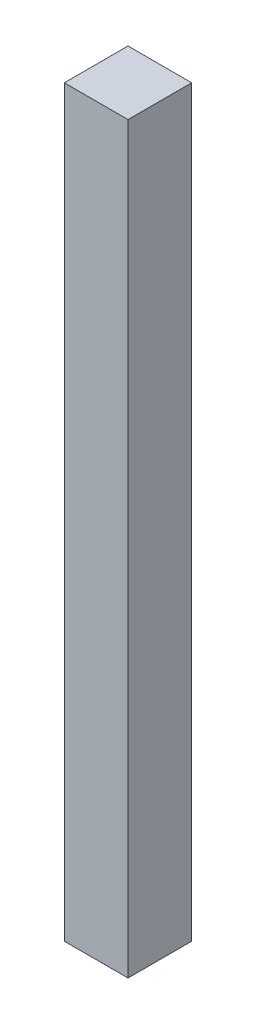
from build123d import *

# Parameters (mm, degrees)
SKETCH1_W           = 60
SKETCH1_H           = 60
BOSS_EXTRUDE1_DEPTH = 700


with BuildPart() as part:
    # Sketch1 → Boss-Extrude1 (new body)
    with BuildSketch(Plane(origin=(0, 0, 0), x_dir=(1, 0, 0), z_dir=(0, 1, 0))):
        with Locations((-58.926858659, -23.233738784)):
            Rectangle(SKETCH1_W, SKETCH1_H)
    extrude(amount=-BOSS_EXTRUDE1_DEPTH)


solid = part.part
